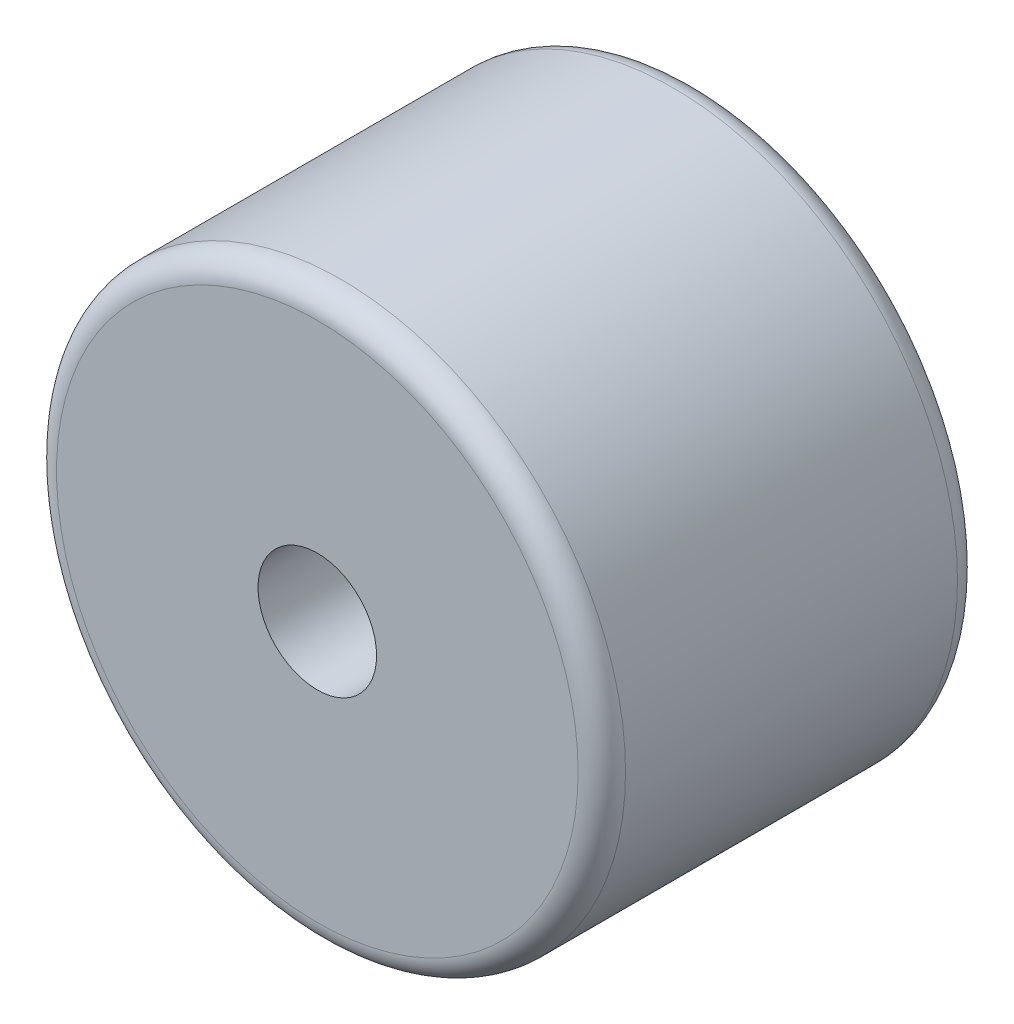
from build123d import *

# Parameters (mm, degrees)
SKETCH1_R           = 12
BOSS_EXTRUDE1_DEPTH = 16
SKETCH2_R           = 2.5
CUT_EXTRUDE1_DEPTH  = 30
FILLET2_R           = 1


with BuildPart() as part:
    # Sketch1 → Boss-Extrude1 (new body)
    with BuildSketch(Plane.XY):
        Circle(SKETCH1_R)
    extrude(amount=BOSS_EXTRUDE1_DEPTH)

    # Sketch2 → Cut-Extrude1 (cut)
    with BuildSketch(Plane.XY.offset(16)):
        Circle(SKETCH2_R)
    extrude(amount=-CUT_EXTRUDE1_DEPTH, mode=Mode.SUBTRACT)

    # Fillet2
    fillet2_edges = [part.edges().sort_by_distance(p)[0] for p in [
        (-12, 0, 0),
        (-12, 0, 16),
    ]]
    fillet(fillet2_edges, radius=FILLET2_R)


solid = part.part
